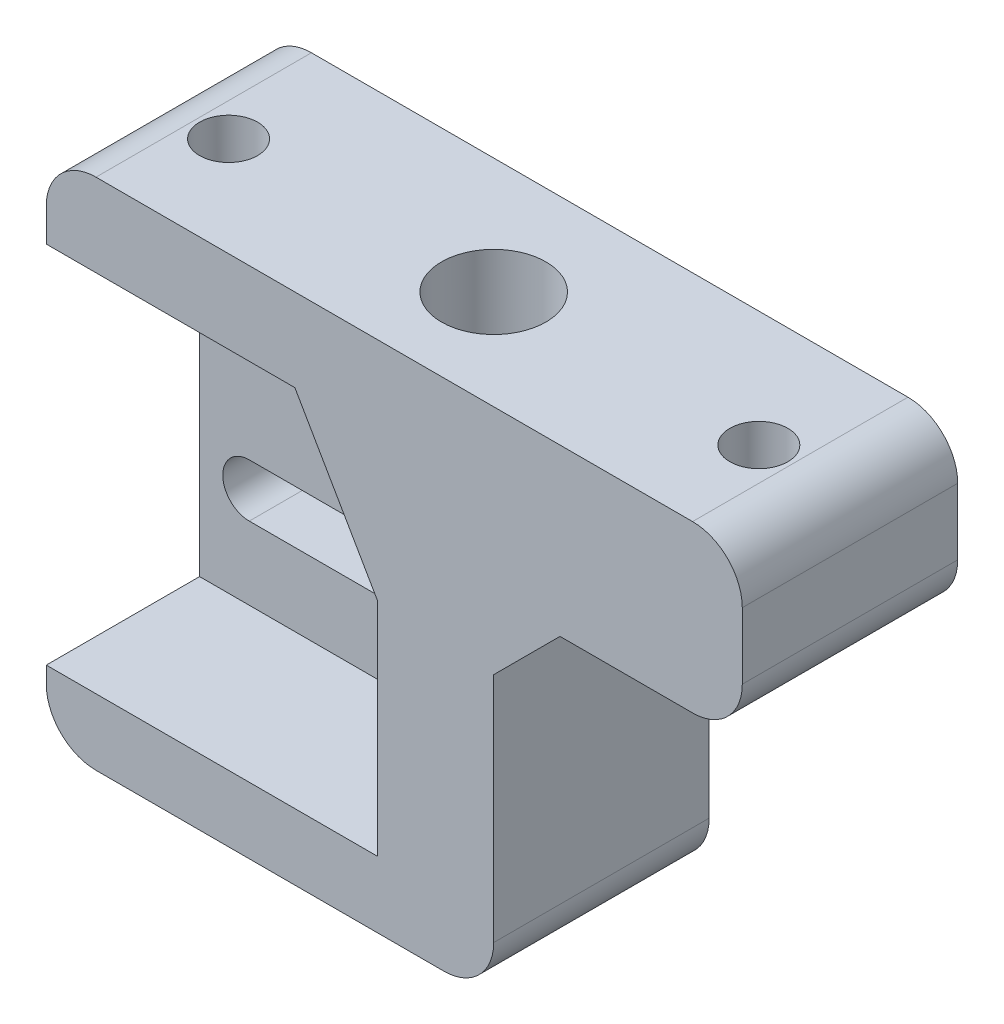
from build123d import *

# Parameters (mm, degrees)
ESQUISSE1_W                   = 30
ESQUISSE1_H                   = 40
BOSS_EXTRU_1_DEPTH            = 14
ESQUISSE3_R                   = 3.15
ENL_V_MAT_EXTRU_1_DEPTH       = 30
ESQUISSE4_W                   = 15
ESQUISSE4_H                   = 22
ENL_V_MAT_EXTRU_2_DEPTH       = 10.25
ENL_V_MAT_EXTRU_3_DEPTH       = 4.75
ENL_V_MAT_EXTRU_4_DEPTH       = 10.25
ESQUISSE7_R                   = 1.75
ENL_V_MAT_EXTRU_5_DEPTH       = 15
ENL_V_START                   = -40
ESQUISSE9_W                   = 30
ESQUISSE9_H                   = 1
ENL_V_MAT_EXTRU_9_DEPTH       = 40
ENL_V_START_2                 = -13
ESQUISSE11_W                  = 30
ESQUISSE11_H                  = 9
ENL_V_MAT_EXTRU_10_DEPTH      = 13
ESQUISSE12_W                  = 15
ESQUISSE12_H                  = 13
BOSS_EXTRU_2_DEPTH            = 10
ESQUISSE13_R                  = 1.75
ENL_V_MAT_EXTRU_11_DEPTH      = 12
CHANFREIN1_SIZE               = 4
ESQUISSE14_W                  = 3
ESQUISSE14_H                  = 31
ENL_V_MAT_EXTRU_12_DEPTH      = 1
ENL_V_MAT_EXTRU_12_DEPTH_BACK = 14
CONG_1_R                      = 3


with BuildPart() as part:
    # Esquisse1 → Boss.-Extru.1 (new body)
    with BuildSketch(Plane.XY):
        with Locations((15, 20)):
            Rectangle(ESQUISSE1_W, ESQUISSE1_H)
    extrude(amount=BOSS_EXTRU_1_DEPTH)

    # Esquisse3 → Enlèv. mat.-Extru.1 (cut)
    with BuildSketch(Plane(origin=(0, 40, 0), x_dir=(1, 0, 0), z_dir=(0, 1, 0))):
        with Locations((24, -7)):
            Circle(ESQUISSE3_R)
    extrude(amount=-ENL_V_MAT_EXTRU_1_DEPTH, mode=Mode.SUBTRACT)

    # Esquisse4 → Enlèv. mat.-Extru.2 (cut)
    with BuildSketch(Plane.XY.offset(14)):
        with Locations((7.5, 24)):
            Rectangle(ESQUISSE4_W, ESQUISSE4_H)
    extrude(amount=-ENL_V_MAT_EXTRU_2_DEPTH, mode=Mode.SUBTRACT)

    # Esquisse5 → Enlèv. mat.-Extru.3 (cut, through all)
    with BuildSketch(Plane.XY.offset(3.75)):
        with BuildLine():
            Line((6, 30.6), (14, 30.6))
            ThreePointArc((14, 30.6), (15.6, 29), (14, 27.4))
            Line((14, 27.4), (6, 27.4))
            ThreePointArc((6, 27.4), (4.4, 29), (6, 30.6))
        make_face()
        with BuildLine():
            Line((6, 17.4), (14, 17.4))
            ThreePointArc((14, 17.4), (15.6, 19), (14, 20.6))
            Line((14, 20.6), (6, 20.6))
            ThreePointArc((6, 20.6), (4.4, 19), (6, 17.4))
        make_face()
    extrude(amount=-ENL_V_MAT_EXTRU_3_DEPTH, mode=Mode.SUBTRACT)

    # Esquisse6 → Enlèv. mat.-Extru.4 (cut)
    with BuildSketch(Plane.XY.offset(14)):
        Polygon((15, 35), (18, 35), (23, 26.339745962), (23, 13), (15, 13), align=None)
    extrude(amount=-ENL_V_MAT_EXTRU_4_DEPTH, mode=Mode.SUBTRACT)

    # Esquisse7 → Enlèv. mat.-Extru.5 (cut, through all)
    with BuildSketch(Plane.XY.offset(14)):
        with Locations((5, 6.5)):
            Circle(ESQUISSE7_R)
        with Locations((25, 6.5)):
            Circle(ESQUISSE7_R)
    extrude(amount=-ENL_V_MAT_EXTRU_5_DEPTH, mode=Mode.SUBTRACT)

    # Esquisse9 → Enlèv. mat.-Extru.9 (cut)
    with BuildSketch(Plane(origin=(0, 40, 0), x_dir=(1, 0, 0), z_dir=(0, 1, 0)).offset(ENL_V_START)):
        with Locations((15, -13.5)):
            Rectangle(ESQUISSE9_W, ESQUISSE9_H)
    extrude(amount=ENL_V_MAT_EXTRU_9_DEPTH, mode=Mode.SUBTRACT)

    # Esquisse11 → Enlèv. mat.-Extru.10 (cut)
    with BuildSketch(Plane.XY.offset(13).offset(ENL_V_START_2)):
        with Locations((15, 4.5)):
            Rectangle(ESQUISSE11_W, ESQUISSE11_H)
    extrude(amount=ENL_V_MAT_EXTRU_10_DEPTH, mode=Mode.SUBTRACT)

    # Esquisse12 → Boss.-Extru.2 (add)
    with BuildSketch(Plane(origin=(0, 40, 0), x_dir=(1, 0, 0), z_dir=(0, 1, 0))):
        with Locations((37.5, -6.5)):
            Rectangle(ESQUISSE12_W, ESQUISSE12_H)
    extrude(amount=-BOSS_EXTRU_2_DEPTH)

    # Esquisse13 → Enlèv. mat.-Extru.11 (cut)
    with BuildSketch(Plane(origin=(0, 40, 0), x_dir=(1, 0, 0), z_dir=(0, 1, 0))):
        with Locations((40, -7)):
            Circle(ESQUISSE13_R)
        with Locations((8, -7)):
            Circle(ESQUISSE13_R)
    extrude(amount=-ENL_V_MAT_EXTRU_11_DEPTH, mode=Mode.SUBTRACT)

    # Chanfrein1
    chanfrein1_edges = [part.edges().sort_by_distance(p)[0] for p in [
        (30, 30, 6.5),
    ]]
    chamfer(chanfrein1_edges, length=CHANFREIN1_SIZE)

    # Esquisse14 → Enlèv. mat.-Extru.12 (cut, two sides)
    with BuildSketch(Plane.XY.offset(13)) as enl_v_mat_extru_12_sk:
        with Locations((1.5, 24.5)):
            Rectangle(ESQUISSE14_W, ESQUISSE14_H)
    extrude(amount=ENL_V_MAT_EXTRU_12_DEPTH, mode=Mode.SUBTRACT)
    extrude(enl_v_mat_extru_12_sk.sketch, amount=-ENL_V_MAT_EXTRU_12_DEPTH_BACK, mode=Mode.SUBTRACT)

    # Congé1
    cong_1_edges = [part.edges().sort_by_distance(p)[0] for p in [
        (30, 9, 6.5),
        (45, 30, 6.5),
        (45, 40, 6.5),
        (3, 9, 6.5),
        (3, 40, 6.5),
    ]]
    fillet(cong_1_edges, radius=CONG_1_R)


solid = part.part
